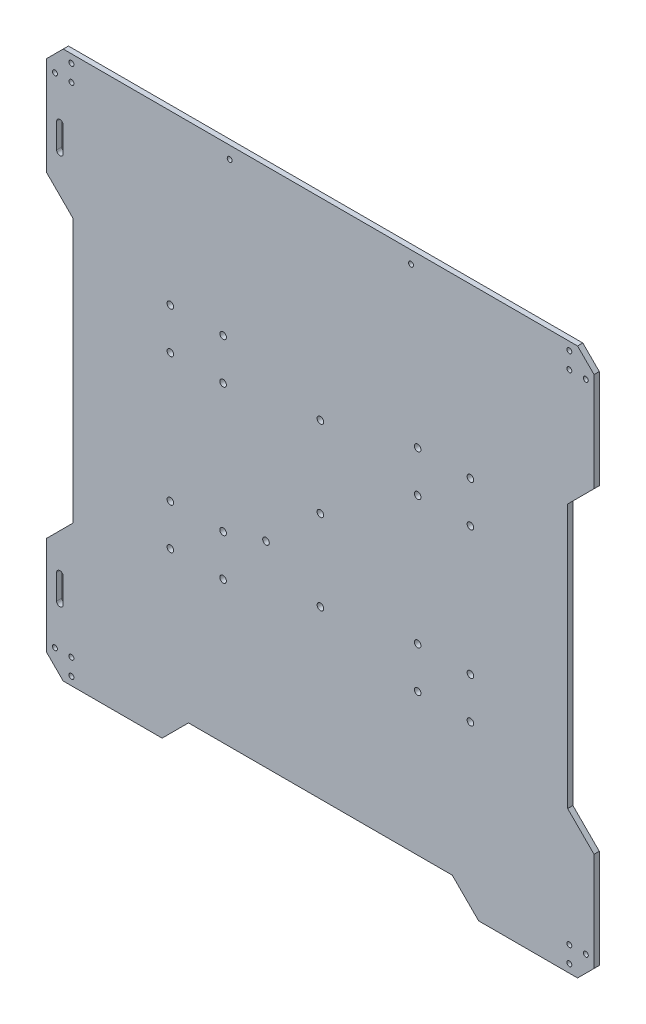
from build123d import *

# Parameters (mm, degrees)
SKETCH1_R           = 2
SKETCH1_R_2         = 1.5
BOSS_EXTRUDE1_DEPTH = 3.175
CUT_EXTRUDE1_DEPTH  = 4.175
CHAMFER1_SIZE       = 10


with BuildPart() as part:
    # Sketch1 → Boss-Extrude1 (new body)
    with BuildSketch(Plane.XY):
        Polygon((166, 166), (166, 96), (150, 80), (150, -80), (166, -96), (166, -166), (96, -166), (80, -150), (-80, -150), (-96, -166), (-166, -166), (-166, -96), (-150, -80), (-150, 80), (-166, 96), (-166, 166), align=None)
        with Locations((-91, 64)):
            Circle(SKETCH1_R, mode=Mode.SUBTRACT)
        with Locations((-91, 39)):
            Circle(SKETCH1_R, mode=Mode.SUBTRACT)
        with Locations((-59, 39)):
            Circle(SKETCH1_R, mode=Mode.SUBTRACT)
        with Locations((-59, 64)):
            Circle(SKETCH1_R, mode=Mode.SUBTRACT)
        with Locations((59, 39)):
            Circle(SKETCH1_R, mode=Mode.SUBTRACT)
        with Locations((59, 64)):
            Circle(SKETCH1_R, mode=Mode.SUBTRACT)
        with Locations((91, 39)):
            Circle(SKETCH1_R, mode=Mode.SUBTRACT)
        with Locations((91, 64)):
            Circle(SKETCH1_R, mode=Mode.SUBTRACT)
        with Locations((59, -64)):
            Circle(SKETCH1_R, mode=Mode.SUBTRACT)
        with Locations((59, -39)):
            Circle(SKETCH1_R, mode=Mode.SUBTRACT)
        with Locations((91, -39)):
            Circle(SKETCH1_R, mode=Mode.SUBTRACT)
        with Locations((91, -64)):
            Circle(SKETCH1_R, mode=Mode.SUBTRACT)
        with Locations((-91, -64)):
            Circle(SKETCH1_R, mode=Mode.SUBTRACT)
        with Locations((-59, -64)):
            Circle(SKETCH1_R, mode=Mode.SUBTRACT)
        with Locations((-59, -39)):
            Circle(SKETCH1_R, mode=Mode.SUBTRACT)
        with Locations((-91, -39)):
            Circle(SKETCH1_R, mode=Mode.SUBTRACT)
        with Locations((-33, -31)):
            Circle(SKETCH1_R, mode=Mode.SUBTRACT)
        Circle(SKETCH1_R, mode=Mode.SUBTRACT)
        with Locations((0, 49)):
            Circle(SKETCH1_R, mode=Mode.SUBTRACT)
        with Locations((0, -49)):
            Circle(SKETCH1_R, mode=Mode.SUBTRACT)
        with Locations((-151, 161)):
            Circle(SKETCH1_R_2, mode=Mode.SUBTRACT)
        with Locations((-161, 151)):
            Circle(SKETCH1_R_2, mode=Mode.SUBTRACT)
        with Locations((151, 161)):
            Circle(SKETCH1_R_2, mode=Mode.SUBTRACT)
        with Locations((161, 151)):
            Circle(SKETCH1_R_2, mode=Mode.SUBTRACT)
        with Locations((161, -151)):
            Circle(SKETCH1_R_2, mode=Mode.SUBTRACT)
        with Locations((151, -161)):
            Circle(SKETCH1_R_2, mode=Mode.SUBTRACT)
        with Locations((-151, -161)):
            Circle(SKETCH1_R_2, mode=Mode.SUBTRACT)
        with Locations((-161, -151)):
            Circle(SKETCH1_R_2, mode=Mode.SUBTRACT)
        with Locations((-151, 151)):
            Circle(SKETCH1_R_2, mode=Mode.SUBTRACT)
        with Locations((151, 151)):
            Circle(SKETCH1_R_2, mode=Mode.SUBTRACT)
        with Locations((151, -151)):
            Circle(SKETCH1_R_2, mode=Mode.SUBTRACT)
        with Locations((-151, -151)):
            Circle(SKETCH1_R_2, mode=Mode.SUBTRACT)
        with Locations((-55, 158.5)):
            Circle(SKETCH1_R_2, mode=Mode.SUBTRACT)
        with Locations((55, 158.5)):
            Circle(SKETCH1_R_2, mode=Mode.SUBTRACT)
    extrude(amount=BOSS_EXTRUDE1_DEPTH)

    # Sketch2 → Cut-Extrude1 (cut, through all)
    with BuildSketch(Plane.XY.offset(3.175)):
        with BuildLine():
            Line((-160, 126), (-160, 111))
            ThreePointArc((-160, 111), (-158, 109), (-156, 111))
            Line((-156, 111), (-156, 126))
            ThreePointArc((-156, 126), (-158, 128), (-160, 126))
        make_face()
        with BuildLine():
            Line((-156, -111), (-156, -126))
            ThreePointArc((-156, -126), (-158, -128), (-160, -126))
            Line((-160, -126), (-160, -111))
            ThreePointArc((-160, -111), (-158, -109), (-156, -111))
        make_face()
    extrude(amount=-CUT_EXTRUDE1_DEPTH, mode=Mode.SUBTRACT)

    # Chamfer1
    chamfer1_edges = [part.edges().sort_by_distance(p)[0] for p in [
        (166, -166, 1.5875),
        (-166, -166, 1.5875),
        (-166, 166, 1.5875),
        (166, 166, 1.5875),
    ]]
    chamfer(chamfer1_edges, length=CHAMFER1_SIZE)


solid = part.part
